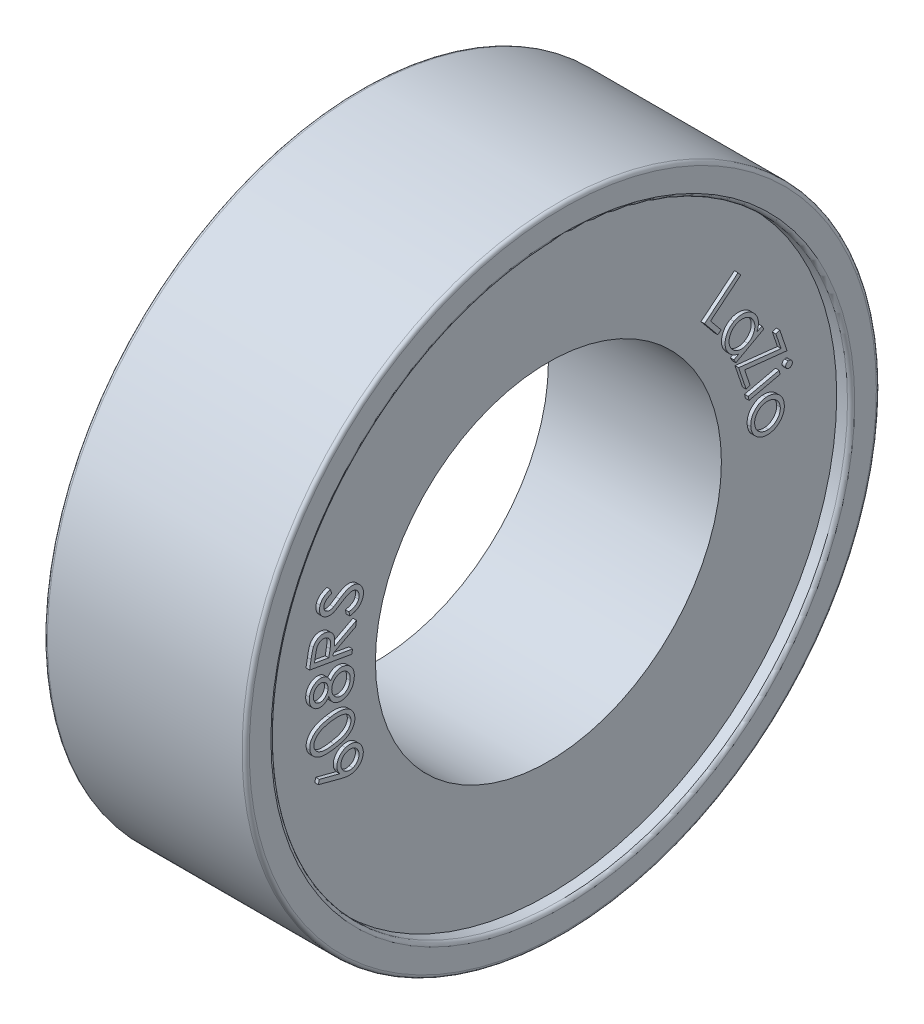
from build123d import *

# Parameters (mm, degrees)
SKETCH1_R           = 10
SKETCH1_R_2         = 6
BOSS_EXTRUDE1_DEPTH = 3
SKETCH1_3_R         = 11
SKETCH1_3_R_2       = 10
BOSS_EXTRUDE2_DEPTH = 3.5
FILLET1_R           = 0.125
BOSS_EXTRUDE3_DEPTH = 0.125
BOSS_EXTRUDE4_DEPTH = 0.125


with BuildPart() as part:
    # Sketch1 → Boss-Extrude1 (new, symmetric)
    with BuildSketch(Plane(origin=(0, 0, 0), x_dir=(0, 0, -1), z_dir=(1, 0, 0))):
        Circle(SKETCH1_R)
        Circle(SKETCH1_R_2, mode=Mode.SUBTRACT)
    extrude(amount=BOSS_EXTRUDE1_DEPTH, both=True)



with BuildPart() as body_2:
    # Sketch1_3 → Boss-Extrude2 (new, symmetric)
    with BuildSketch(Plane(origin=(0, 0, 0), x_dir=(0, 0, -1), z_dir=(1, 0, 0))):
        Circle(SKETCH1_3_R)
        Circle(SKETCH1_3_R_2, mode=Mode.SUBTRACT)
    extrude(amount=BOSS_EXTRUDE2_DEPTH, both=True)

    # Fillet1
    fillet1_edges = [body_2.edges().sort_by_distance(p)[0] for p in [
        (-3.5, 0, 10),
        (3.5, 0, 10),
        (3.5, 0, 11),
        (-3.5, 0, 11),
    ]]
    fillet(fillet1_edges, radius=FILLET1_R)


with BuildPart() as part_1:
    add(part.part)

    add(body_2.part)  # Boss-Extrude3 merges body 2
    # Sketch2 → Boss-Extrude3 (add)
    # profile 1 of 6: a face of its own
    with BuildSketch(Plane(origin=(3, 0, 0), x_dir=(0, 0, -1), z_dir=(1, 0, 0))):
        Polygon((7.876173814, 1.880145542), (7.908024775, 1.741022946), (6.835308429, 1.495530158), (6.803457468, 1.634652754), align=None)
    # profile 2 of 6: a face of its own
    with BuildSketch(Plane(origin=(3, 0, 0), x_dir=(0, 0, -1), z_dir=(1, 0, 0))):
        Polygon((7.765165052, 3.027508204), (7.90128284, 3.073481762), (8.152785244, 2.330392819), (6.681330917, 2.488746185), (6.870934283, 1.929250992), (6.733915052, 1.882976954), (6.470994379, 2.659719742), (7.944552071, 2.497760608), align=None)
    # profile 3 of 6: a face of its own
    with BuildSketch(Plane(origin=(3, 0, 0), x_dir=(0, 0, -1), z_dir=(1, 0, 0))):
        with BuildLine():
            Line((7.348067222, 3.385418884), (6.377514338, 2.854168884))
            Line((6.377514338, 2.854168884), (6.310206645, 2.977065519))
            Line((6.310206645, 2.977065519), (6.476973472, 3.068411673))
            add(Edge.make_bspline(
                [(6.476973472, 3.068411673), (6.432912301, 3.076882848), (6.368707025, 3.094720381), (6.289951586, 3.132117651), (6.23634493, 3.164895224), (6.187594105, 3.20363805), (6.128638882, 3.263733971), (6.091998896, 3.315978449), (6.071624915, 3.353567923)],
                knots=[0, 0, 0, 0, 0.262596255, 0.387041454, 0.508790467, 0.629257764, 0.750192583, 1, 1, 1, 1], degree=3))
            add(Edge.make_bspline(
                [(6.071624915, 3.353567923), (6.053862987, 3.386992389), (6.03048371, 3.438510469), (6.011799468, 3.510747841), (6.003750028, 3.564940911), (6.000958697, 3.619794764), (6.003923914, 3.675313512), (6.013279383, 3.731385415), (6.027465546, 3.787586409), (6.047230542, 3.842211504), (6.071118785, 3.894366115), (6.100316638, 3.942551382), (6.13344444, 3.987746849), (6.171463457, 4.029304679), (6.229103175, 4.080496339), (6.277591205, 4.113261636), (6.312310011, 4.131813115)],
                knots=[0, 0, 0, 0, 0.12543495, 0.18605548, 0.246388948, 0.30646051, 0.367542389, 0.429994028, 0.494310924, 0.559107792, 0.621987258, 0.683837808, 0.745229205, 0.807172064, 0.869852883, 1, 1, 1, 1], degree=3))
            add(Edge.make_bspline(
                [(6.312310011, 4.131813115), (6.346167536, 4.150308861), (6.398885364, 4.173371613), (6.47195978, 4.193368531), (6.526830045, 4.202508054), (6.582318261, 4.205774588), (6.638403949, 4.203376986), (6.6949965, 4.194989636), (6.751549432, 4.181673712), (6.806615153, 4.163143671), (6.85903, 4.140416863), (6.907499996, 4.11266275), (6.952242968, 4.080475083), (6.993840358, 4.044454205), (7.043953259, 3.988714725), (7.076218653, 3.941983784), (7.094160972, 3.908255423)],
                knots=[0, 0, 0, 0, 0.1280267, 0.190038322, 0.251025809, 0.312298894, 0.374184765, 0.436990482, 0.50189608, 0.566753992, 0.629565866, 0.69120574, 0.751719409, 0.812259549, 0.873437884, 1, 1, 1, 1], degree=3))
            add(Edge.make_bspline(
                [(7.094160972, 3.908255423), (7.115257889, 3.870104386), (7.140326856, 3.809999175), (7.157881464, 3.726326645), (7.163188956, 3.663831995), (7.159947329, 3.600845258), (7.145191525, 3.514408491), (7.121470476, 3.451582236), (7.102273953, 3.410659269)],
                knots=[0, 0, 0, 0, 0.252388809, 0.373833537, 0.493677479, 0.614414294, 0.737947537, 1, 1, 1, 1], degree=3))
            Line((7.102273953, 3.410659269), (7.28075953, 3.508315519))
            Line((7.28075953, 3.508315519), (7.348067222, 3.385418884))
        make_face()
        with BuildLine():
            add(Edge.make_bspline(
                [(6.979076838, 3.832534269), (6.960583274, 3.866312744), (6.926929489, 3.913709089), (6.870081876, 3.965543712), (6.822818599, 3.998229251), (6.771849664, 4.0248383), (6.717386415, 4.043914664), (6.66028237, 4.055562812), (6.601313925, 4.060085083), (6.542202387, 4.056939042), (6.465105723, 4.04406133), (6.410589038, 4.022217192), (6.376612895, 4.003808307)],
                knots=[0, 0, 0, 0, 0.166129634, 0.248055287, 0.330600145, 0.413273703, 0.495228948, 0.578574358, 0.663901406, 0.749523051, 0.833234679, 1, 1, 1, 1], degree=3))
            add(Edge.make_bspline(
                [(6.376612895, 4.003808307), (6.342533493, 3.985585894), (6.295564594, 3.950655625), (6.242678081, 3.892880769), (6.208288267, 3.844043935), (6.179845492, 3.791529), (6.158392595, 3.736682152), (6.145184015, 3.680008055), (6.139506876, 3.622426331), (6.141226663, 3.565035601), (6.153715265, 3.490015484), (6.174718897, 3.436763056), (6.192718665, 3.40344773)],
                knots=[0, 0, 0, 0, 0.166299711, 0.250040083, 0.33677935, 0.423140545, 0.506937675, 0.589889477, 0.673200136, 0.75571473, 0.836711587, 1, 1, 1, 1], degree=3))
            add(Edge.make_bspline(
                [(6.192718665, 3.40344773), (6.211315652, 3.369912665), (6.245203252, 3.32266503), (6.302307895, 3.270306027), (6.35011982, 3.236250512), (6.401647383, 3.208424677), (6.455686325, 3.187948142), (6.511441693, 3.175547673), (6.568477855, 3.171083332), (6.626008939, 3.174373082), (6.703434193, 3.189739124), (6.759052427, 3.212364663), (6.794281165, 3.231873211)],
                knots=[0, 0, 0, 0, 0.164964063, 0.247567707, 0.332184894, 0.416782348, 0.498700416, 0.579895142, 0.661555771, 0.743958169, 0.826908066, 1, 1, 1, 1], degree=3))
            add(Edge.make_bspline(
                [(6.794281165, 3.231873211), (6.821183374, 3.246809242), (6.859730545, 3.27161905), (6.904490541, 3.311825464), (6.934604244, 3.343486734), (6.960080786, 3.378525765), (6.98250809, 3.415529576), (7.001221729, 3.455202057), (7.016089288, 3.496875138), (7.02684533, 3.539761068), (7.033571558, 3.582704502), (7.035745237, 3.625413992), (7.033227074, 3.667693212), (7.026655653, 3.709702965), (7.011520056, 3.765997388), (6.993335444, 3.806420939), (6.979076838, 3.832534269)],
                knots=[0, 0, 0, 0, 0.131761822, 0.194869765, 0.257000435, 0.31825815, 0.379747577, 0.441830974, 0.505512033, 0.568679555, 0.630656458, 0.691130331, 0.751199285, 0.811483215, 0.872685488, 1, 1, 1, 1], degree=3))
        make_face(mode=Mode.SUBTRACT)
    # profile 4 of 6: a face of its own
    with BuildSketch(Plane(origin=(3, 0, 0), x_dir=(0, 0, -1), z_dir=(1, 0, 0))):
        Polygon((6.451970007, 5.521097553), (6.54722241, 5.404511014), (5.499145487, 4.546337937), (5.864229622, 4.100424476), (5.752150295, 4.008777841), (5.291813757, 4.571277841), align=None)
    # profile 5 of 6: a face of its own
    with BuildSketch(Plane(origin=(3, 0, 0), x_dir=(0, 0, -1), z_dir=(1, 0, 0))):
        with BuildLine():
            add(Edge.make_bspline(
                [(8.055357572, 0.767794244), (8.059184284, 0.726897516), (8.058144296, 0.666003934), (8.045488516, 0.586954314), (8.02923768, 0.531035823), (8.007553781, 0.477190051), (7.970096763, 0.407403163), (7.932669377, 0.360263326), (7.905417668, 0.330594725)],
                knots=[0, 0, 0, 0, 0.258156998, 0.381466926, 0.502764496, 0.623789911, 0.746181412, 1, 1, 1, 1], degree=3))
            add(Edge.make_bspline(
                [(7.905417668, 0.330594725), (7.879976328, 0.303850369), (7.839051771, 0.266872592), (7.778527786, 0.226257661), (7.731281318, 0.200606223), (7.681624771, 0.179782466), (7.611580084, 0.157858719), (7.556624634, 0.148617755), (7.51929988, 0.145799052)],
                knots=[0, 0, 0, 0, 0.252774475, 0.375817167, 0.498233518, 0.620232449, 0.743845074, 1, 1, 1, 1], degree=3))
            add(Edge.make_bspline(
                [(7.51929988, 0.145799052), (7.481713939, 0.142743109), (7.425539518, 0.143025749), (7.352064745, 0.153832544), (7.299056277, 0.167658421), (7.247144457, 0.185750261), (7.197004175, 0.209909215), (7.148224669, 0.238828494), (7.101285992, 0.272506183), (7.057803001, 0.310633518), (7.018589563, 0.352306252), (6.984865885, 0.397494667), (6.956390689, 0.446126612), (6.932881275, 0.497839168), (6.908379872, 0.572694606), (6.898613481, 0.631896826), (6.895201322, 0.67224136)],
                knots=[0, 0, 0, 0, 0.124270872, 0.184364268, 0.24434146, 0.30459427, 0.365290492, 0.427462078, 0.491327071, 0.555432271, 0.61780079, 0.679606617, 0.740873944, 0.803227606, 0.866497567, 1, 1, 1, 1], degree=3))
            add(Edge.make_bspline(
                [(6.895201322, 0.67224136), (6.891888787, 0.712789676), (6.891735688, 0.773128291), (6.904163742, 0.851200247), (6.918414262, 0.906386982), (6.938772317, 0.959059364), (6.964664891, 1.009208315), (6.996647592, 1.056612022), (7.033364176, 1.101286665), (7.073855498, 1.142473681), (7.117356403, 1.179048684), (7.163157283, 1.210706356), (7.211145144, 1.237566639), (7.261272152, 1.259757038), (7.332020048, 1.282287819), (7.387406876, 1.291805258), (7.424948918, 1.294837513)],
                knots=[0, 0, 0, 0, 0.134008452, 0.197427109, 0.259802779, 0.321276187, 0.382914705, 0.4451866, 0.509142043, 0.573021808, 0.635033942, 0.695942449, 0.756018074, 0.815806221, 0.876071533, 1, 1, 1, 1], degree=3))
            add(Edge.make_bspline(
                [(7.424948918, 1.294837513), (7.462018611, 1.298167889), (7.517458528, 1.297955366), (7.590002416, 1.287916664), (7.642235349, 1.275312925), (7.692884653, 1.257642872), (7.759035677, 1.227612356), (7.805564327, 1.198093796), (7.834804688, 1.175546648)],
                knots=[0, 0, 0, 0, 0.255344777, 0.378927283, 0.501994248, 0.623540367, 0.746616934, 1, 1, 1, 1], degree=3))
            add(Edge.make_bspline(
                [(7.834804688, 1.175546648), (7.867023682, 1.151108877), (7.911335974, 1.110255745), (7.959939322, 1.047547736), (7.990947634, 0.998242433), (8.015537111, 0.945122124), (8.041784601, 0.869176558), (8.05174562, 0.808742047), (8.055357572, 0.767794244)],
                knots=[0, 0, 0, 0, 0.253736058, 0.375519302, 0.496864155, 0.618288685, 0.741877034, 1, 1, 1, 1], degree=3))
        make_face()
        with BuildLine():
            add(Edge.make_bspline(
                [(7.916234976, 0.756375975), (7.913563429, 0.784825479), (7.906816312, 0.827068755), (7.888343415, 0.8803605), (7.870916803, 0.918229244), (7.849115998, 0.953936396), (7.823691763, 0.987964801), (7.794124496, 1.019820552), (7.760859593, 1.049279398), (7.725302676, 1.076101632), (7.687838497, 1.099186863), (7.648808852, 1.117856938), (7.608493489, 1.132672811), (7.566708789, 1.143287342), (7.508495554, 1.15163137), (7.463851349, 1.152062124), (7.433963341, 1.149404821)],
                knots=[0, 0, 0, 0, 0.124131366, 0.184310496, 0.244179873, 0.30460785, 0.365432795, 0.428152289, 0.492772129, 0.557941713, 0.621128956, 0.683311956, 0.745300378, 0.807154671, 0.869949359, 1, 1, 1, 1], degree=3))
            add(Edge.make_bspline(
                [(7.433963341, 1.149404821), (7.395068035, 1.146149458), (7.337324377, 1.13468523), (7.265396838, 1.104090888), (7.215017982, 1.074457088), (7.168851653, 1.039280084), (7.128466849, 0.999003059), (7.094386785, 0.954062008), (7.067111904, 0.904730716), (7.046771858, 0.852225667), (7.028687525, 0.778655127), (7.026704963, 0.721390375), (7.029816707, 0.683359148)],
                knots=[0, 0, 0, 0, 0.170442258, 0.2544837, 0.340111224, 0.424929136, 0.507158968, 0.588300793, 0.670296699, 0.752376476, 0.833386286, 1, 1, 1, 1], degree=3))
            add(Edge.make_bspline(
                [(7.029816707, 0.683359148), (7.032284841, 0.645263555), (7.044781139, 0.589576821), (7.073736506, 0.51971076), (7.102753024, 0.471380795), (7.137771113, 0.427283018), (7.178549942, 0.388269677), (7.224895433, 0.355039927), (7.276239175, 0.327954873), (7.330768942, 0.306931044), (7.406809042, 0.288709471), (7.465601385, 0.286049027), (7.504576322, 0.28942886)],
                knots=[0, 0, 0, 0, 0.166167164, 0.247303675, 0.32927495, 0.411433809, 0.492470089, 0.574874142, 0.659581735, 0.745262385, 0.829371874, 1, 1, 1, 1], degree=3))
            add(Edge.make_bspline(
                [(7.504576322, 0.28942886), (7.534476233, 0.291881438), (7.578611502, 0.299130312), (7.634474047, 0.317654472), (7.673991095, 0.334606651), (7.711247351, 0.355957095), (7.746548411, 0.381034469), (7.779903466, 0.409866143), (7.810659707, 0.442270206), (7.83841112, 0.477005144), (7.862118622, 0.513550991), (7.882401504, 0.550916226), (7.897583021, 0.589848175), (7.908914282, 0.629881244), (7.918116226, 0.685365378), (7.918617744, 0.727983098), (7.916234976, 0.756375975)],
                knots=[0, 0, 0, 0, 0.130233876, 0.192895457, 0.25497576, 0.316473896, 0.378809175, 0.442580425, 0.507432172, 0.57237848, 0.635172512, 0.696212983, 0.756490789, 0.81606117, 0.876426625, 1, 1, 1, 1], degree=3))
        make_face(mode=Mode.SUBTRACT)
    # profile 6 of 6: a face of its own
    with BuildSketch(Plane(origin=(3, 0, 0), x_dir=(0, 0, -1), z_dir=(1, 0, 0))):
        with BuildLine():
            add(Edge.make_bspline(
                [(8.333806025, 1.912296985), (8.336765064, 1.897446884), (8.338914136, 1.873959818), (8.329737705, 1.84444022), (8.319429825, 1.823626357), (8.305379195, 1.804929496), (8.28209068, 1.784496615), (8.26057326, 1.775052676), (8.245464679, 1.771972465)],
                knots=[0, 0, 0, 0, 0.249117155, 0.371430687, 0.499064661, 0.625946242, 0.749600591, 1, 1, 1, 1], degree=3))
            add(Edge.make_bspline(
                [(8.245464679, 1.771972465), (8.230763383, 1.768592647), (8.207723525, 1.76752437), (8.178372711, 1.775987431), (8.15770221, 1.786378234), (8.13899752, 1.800391864), (8.118626782, 1.823619565), (8.109215213, 1.845029351), (8.106041602, 1.860013331)],
                knots=[0, 0, 0, 0, 0.247633667, 0.368743436, 0.497240399, 0.624979881, 0.749470312, 1, 1, 1, 1], degree=3))
            add(Edge.make_bspline(
                [(8.106041602, 1.860013331), (8.102796666, 1.874774103), (8.101311657, 1.898061259), (8.110454423, 1.927346909), (8.120707665, 1.948096386), (8.134763708, 1.966675895), (8.157516971, 1.987160128), (8.178701876, 1.996549689), (8.193481506, 1.999736888)],
                knots=[0, 0, 0, 0, 0.249801647, 0.371625234, 0.500395299, 0.628406273, 0.751929139, 1, 1, 1, 1], degree=3))
            add(Edge.make_bspline(
                [(8.193481506, 1.999736888), (8.208428719, 2.002660136), (8.232026295, 2.004880847), (8.261633718, 1.995663881), (8.282472841, 1.985376663), (8.301015173, 1.971297751), (8.321712321, 1.94862264), (8.330246719, 1.926908593), (8.333806025, 1.912296985)],
                knots=[0, 0, 0, 0, 0.251616485, 0.374360222, 0.502443114, 0.629770967, 0.752634661, 1, 1, 1, 1], degree=3))
        make_face()
    boss_extrude3 = extrude(amount=BOSS_EXTRUDE3_DEPTH)

    # Sketch4 → Boss-Extrude4 (add)
    # profile 1 of 5: a face of its own
    with BuildSketch(Plane(origin=(3, 0, 0), x_dir=(0, 0, -1), z_dir=(1, 0, 0))):
        with BuildLine():
            Line((-7.011638352, 1.941228674), (-7.041385948, 2.086060405))
            add(Edge.make_bspline(
                [(-7.041385948, 2.086060405), (-6.999189148, 2.093026571), (-6.939049017, 2.106640739), (-6.865508848, 2.134904223), (-6.81985023, 2.159549788), (-6.780826987, 2.187869819), (-6.738241827, 2.230352612), (-6.716285381, 2.269326434), (-6.706650371, 2.296697424)],
                knots=[0, 0, 0, 0, 0.309029664, 0.443489335, 0.567781604, 0.682655594, 0.790580454, 1, 1, 1, 1], degree=3))
            add(Edge.make_bspline(
                [(-6.706650371, 2.296697424), (-6.69871505, 2.319794591), (-6.690076521, 2.355756495), (-6.689180664, 2.404744843), (-6.692386723, 2.441143324), (-6.699784287, 2.476513775), (-6.711427561, 2.50975191), (-6.727532085, 2.540250712), (-6.747848597, 2.567446769), (-6.770804188, 2.591846822), (-6.805061489, 2.619205637), (-6.834272853, 2.634165823), (-6.85478739, 2.641048386)],
                knots=[0, 0, 0, 0, 0.17604078, 0.263270306, 0.351550382, 0.438478699, 0.522589002, 0.604153715, 0.685594162, 0.766136813, 0.844585477, 1, 1, 1, 1], degree=3))
            add(Edge.make_bspline(
                [(-6.85478739, 2.641048386), (-6.878599978, 2.649296933), (-6.931351467, 2.658171836), (-6.984026619, 2.649046673), (-7.010436428, 2.641649347)],
                knots=[0, 0, 0, 0, 0.477935315, 1, 1, 1, 1], degree=3))
            add(Edge.make_bspline(
                [(-7.010436428, 2.641649347), (-7.032084619, 2.635898366), (-7.064945013, 2.623015408), (-7.110183865, 2.603423107), (-7.147619374, 2.584151837), (-7.187680138, 2.562569167), (-7.246322637, 2.528445986), (-7.290422342, 2.499580554), (-7.320833063, 2.479690212)],
                knots=[0, 0, 0, 0, 0.19082327, 0.30110578, 0.420820675, 0.550165245, 0.689663337, 1, 1, 1, 1], degree=3))
            add(Edge.make_bspline(
                [(-7.320833063, 2.479690212), (-7.350592662, 2.460071428), (-7.393320066, 2.432179039), (-7.448574844, 2.39831738), (-7.484280945, 2.377653493), (-7.516001447, 2.360036321), (-7.550647453, 2.34302332), (-7.574883255, 2.332229147), (-7.590364313, 2.327646943)],
                knots=[0, 0, 0, 0, 0.344758908, 0.493455668, 0.626712095, 0.743764697, 0.84427525, 1, 1, 1, 1], degree=3))
            add(Edge.make_bspline(
                [(-7.590364313, 2.327646943), (-7.610654263, 2.321041971), (-7.641537478, 2.313866533), (-7.683019024, 2.30892527), (-7.713458444, 2.30773816), (-7.743629128, 2.308822772), (-7.78354879, 2.314231222), (-7.812937851, 2.32162033), (-7.831950852, 2.328548386)],
                knots=[0, 0, 0, 0, 0.260143321, 0.385642153, 0.509156191, 0.631449242, 0.753461146, 1, 1, 1, 1], degree=3))
            add(Edge.make_bspline(
                [(-7.831950852, 2.328548386), (-7.861303718, 2.339357557), (-7.904076499, 2.359310132), (-7.952787908, 2.39789423), (-7.985148227, 2.430608664), (-8.012370107, 2.467495601), (-8.034339862, 2.507717513), (-8.050657207, 2.550990782), (-8.060979523, 2.596913669), (-8.065811242, 2.644231757), (-8.064337698, 2.708310116), (-8.053189546, 2.755462317), (-8.042888352, 2.785880116)],
                knots=[0, 0, 0, 0, 0.167519363, 0.249059235, 0.330763873, 0.412608477, 0.493038911, 0.574804814, 0.658761795, 0.743711501, 0.82825604, 1, 1, 1, 1], degree=3))
            add(Edge.make_bspline(
                [(-8.042888352, 2.785880116), (-8.031322851, 2.81831542), (-8.008459199, 2.865118998), (-7.96560789, 2.919276241), (-7.934763332, 2.950164532), (-7.906488647, 2.972809143), (-7.882447386, 2.989385669), (-7.855492546, 3.004782519), (-7.826282169, 3.020349445), (-7.794167834, 3.03482593), (-7.746485584, 3.05441221), (-7.708674955, 3.066833245), (-7.682611909, 3.074942616)],
                knots=[0, 0, 0, 0, 0.214698089, 0.32089837, 0.428972982, 0.485772709, 0.546336026, 0.610639354, 0.679005404, 0.752421936, 0.829923101, 1, 1, 1, 1], degree=3))
            Line((-7.682611909, 3.074942616), (-7.635736909, 2.929509924))
            add(Edge.make_bspline(
                [(-7.635736909, 2.929509924), (-7.656192219, 2.922487103), (-7.686041613, 2.912829308), (-7.723449114, 2.897765806), (-7.74804471, 2.887042822), (-7.77020799, 2.876289421), (-7.789580987, 2.865046115), (-7.806966944, 2.854491673), (-7.826016416, 2.839572704), (-7.846802665, 2.819847291), (-7.875418264, 2.784601026), (-7.890264615, 2.753674483), (-7.898056621, 2.732394539)],
                knots=[0, 0, 0, 0, 0.189766663, 0.274923552, 0.353598319, 0.425104112, 0.49081079, 0.550037175, 0.603279713, 0.702703188, 0.800802079, 1, 1, 1, 1], degree=3))
            add(Edge.make_bspline(
                [(-7.898056621, 2.732394539), (-7.906877979, 2.706143087), (-7.915462729, 2.665173906), (-7.908616959, 2.61134166), (-7.896327701, 2.574395506), (-7.877396401, 2.541123103), (-7.843828364, 2.503236137), (-7.810252271, 2.484460095), (-7.786578255, 2.476084443)],
                knots=[0, 0, 0, 0, 0.267611967, 0.392726518, 0.517518556, 0.639529123, 0.758147866, 1, 1, 1, 1], degree=3))
            add(Edge.make_bspline(
                [(-7.786578255, 2.476084443), (-7.771459731, 2.470479831), (-7.747788301, 2.465227747), (-7.715492888, 2.462683316), (-7.690391585, 2.463651782), (-7.663760624, 2.467645462), (-7.62361596, 2.478600323), (-7.593157418, 2.490838827), (-7.572635948, 2.501024347)],
                knots=[0, 0, 0, 0, 0.217705713, 0.326461485, 0.437698315, 0.55694839, 0.690118867, 1, 1, 1, 1], degree=3))
            add(Edge.make_bspline(
                [(-7.572635948, 2.501024347), (-7.563482553, 2.505541181), (-7.548406459, 2.515090861), (-7.525203964, 2.529119048), (-7.50178456, 2.544336332), (-7.474033759, 2.562303338), (-7.429100663, 2.592664584), (-7.393155892, 2.616670448), (-7.368008544, 2.633836847)],
                knots=[0, 0, 0, 0, 0.125280758, 0.219260052, 0.333345188, 0.468592883, 0.62569115, 1, 1, 1, 1], degree=3))
            add(Edge.make_bspline(
                [(-7.368008544, 2.633836847), (-7.336662754, 2.654876196), (-7.290881508, 2.684998425), (-7.229613449, 2.720446864), (-7.18748894, 2.742828295), (-7.147652055, 2.762440575), (-7.109813637, 2.778169081), (-7.07439305, 2.79148004), (-7.040650137, 2.800825085), (-7.00837196, 2.807365237), (-6.977126053, 2.812432163), (-6.946476786, 2.814725213), (-6.916559586, 2.815097154), (-6.887436795, 2.81328581), (-6.849622471, 2.80822509), (-6.822215859, 2.800440276), (-6.804306621, 2.794594059)],
                knots=[0, 0, 0, 0, 0.186084148, 0.269899677, 0.348729984, 0.421139088, 0.488610313, 0.550601391, 0.607487179, 0.660923414, 0.712861397, 0.763362853, 0.812231396, 0.860201761, 0.907041439, 1, 1, 1, 1], degree=3))
            add(Edge.make_bspline(
                [(-6.804306621, 2.794594059), (-6.779384777, 2.785989938), (-6.743763613, 2.76917667), (-6.70025545, 2.740538064), (-6.670617581, 2.715736103), (-6.643842738, 2.687540056), (-6.619321875, 2.656402843), (-6.597411111, 2.622072709), (-6.578362995, 2.585035962), (-6.562466771, 2.546251405), (-6.550529767, 2.506589295), (-6.542052797, 2.466613531), (-6.538671848, 2.426174322), (-6.538945516, 2.385436993), (-6.544612343, 2.329959038), (-6.555343772, 2.288962267), (-6.564823448, 2.262142136)],
                knots=[0, 0, 0, 0, 0.121894261, 0.181421904, 0.240656421, 0.300328285, 0.361070903, 0.423823304, 0.488509801, 0.553588768, 0.617526801, 0.679984008, 0.742349972, 0.804932635, 0.868310301, 1, 1, 1, 1], degree=3))
            add(Edge.make_bspline(
                [(-6.564823448, 2.262142136), (-6.572758291, 2.241441795), (-6.584673949, 2.210383128), (-6.606887575, 2.172597606), (-6.624600633, 2.145528085), (-6.644392639, 2.120197446), (-6.665940643, 2.096057066), (-6.689575077, 2.073793756), (-6.715039376, 2.052717769), (-6.742960881, 2.033465998), (-6.77319189, 2.015426164), (-6.806276685, 1.999134303), (-6.842055855, 1.984503052), (-6.880594238, 1.971307138), (-6.937033888, 1.955324667), (-6.981250132, 1.946284172), (-7.011638352, 1.941228674)],
                knots=[0, 0, 0, 0, 0.114729196, 0.170788225, 0.226006166, 0.281655852, 0.336582454, 0.392912727, 0.449126573, 0.507080718, 0.567830534, 0.630734282, 0.697283978, 0.767276625, 0.840936454, 1, 1, 1, 1], degree=3))
        make_face()
    # profile 2 of 5: a face of its own
    with BuildSketch(Plane(origin=(3, 0, 0), x_dir=(0, 0, -1), z_dir=(1, 0, 0))):
        with BuildLine():
            Line((-8.408067858, 1.01721813), (-8.357286608, 1.308984957))
            add(Edge.make_bspline(
                [(-8.357286608, 1.308984957), (-8.350617936, 1.346385285), (-8.3411862, 1.400051656), (-8.326818614, 1.46782324), (-8.316913337, 1.511201231), (-8.307399187, 1.549600162), (-8.295887672, 1.591045365), (-8.286629571, 1.619398352), (-8.279462089, 1.636208515)],
                knots=[0, 0, 0, 0, 0.338375124, 0.485158431, 0.616939651, 0.734632706, 0.837436261, 1, 1, 1, 1], degree=3))
            add(Edge.make_bspline(
                [(-8.279462089, 1.636208515), (-8.271073105, 1.656540378), (-8.255869767, 1.685524154), (-8.232222567, 1.721746552), (-8.212276257, 1.746295641), (-8.190704796, 1.769123811), (-8.1673787, 1.790149813), (-8.141931031, 1.809083246), (-8.115018053, 1.82626546), (-8.086532785, 1.84088703), (-8.056957093, 1.85312634), (-8.026185523, 1.862026037), (-7.994523041, 1.868354663), (-7.961952562, 1.872043734), (-7.916525468, 1.872672595), (-7.882120811, 1.869140328), (-7.859089493, 1.865174861)],
                knots=[0, 0, 0, 0, 0.126763836, 0.188483442, 0.249325304, 0.309019679, 0.369597394, 0.430288062, 0.491864054, 0.553648582, 0.614829948, 0.676283742, 0.738176322, 0.800985165, 0.865154285, 1, 1, 1, 1], degree=3))
            add(Edge.make_bspline(
                [(-7.859089493, 1.865174861), (-7.821233685, 1.858756084), (-7.766375342, 1.842616654), (-7.701019253, 1.806210755), (-7.657920842, 1.773430124), (-7.620337092, 1.734938836), (-7.589742071, 1.690604349), (-7.565410235, 1.641492028), (-7.55136202, 1.596622419), (-7.54339578, 1.558068973), (-7.539267327, 1.5264315), (-7.536959051, 1.492519723), (-7.536273895, 1.45640512), (-7.538081415, 1.418124564), (-7.541925311, 1.362431396), (-7.548477464, 1.319780217), (-7.55320007, 1.29065563)],
                knots=[0, 0, 0, 0, 0.15573696, 0.229158099, 0.302153748, 0.374503054, 0.446241556, 0.519590828, 0.595854893, 0.63606234, 0.679066444, 0.725055894, 0.77377908, 0.825377234, 0.880333361, 1, 1, 1, 1], degree=3))
            Line((-7.55320007, 1.29065563), (-6.780363531, 1.698708515))
            Line((-6.780363531, 1.698708515), (-6.811914012, 1.517518611))
            Line((-6.811914012, 1.517518611), (-7.58445007, 1.110667649))
            Line((-7.58445007, 1.110667649), (-7.599173627, 1.026833515))
            Line((-7.599173627, 1.026833515), (-6.918284204, 0.908143611))
            Line((-6.918284204, 0.908143611), (-6.94382507, 0.761809476))
            Line((-6.94382507, 0.761809476), (-8.408067858, 1.01721813))
        make_face()
        with BuildLine():
            Line((-8.239197666, 1.138612361), (-7.741301031, 1.051773419))
            Line((-7.741301031, 1.051773419), (-7.695627954, 1.303275822))
            add(Edge.make_bspline(
                [(-7.695627954, 1.303275822), (-7.69184716, 1.326143248), (-7.68634332, 1.35928484), (-7.682416689, 1.40231004), (-7.680096871, 1.431040755), (-7.67939821, 1.457632001), (-7.680466105, 1.481883815), (-7.681978138, 1.504009534), (-7.686455238, 1.530189474), (-7.694842262, 1.560372906), (-7.710103154, 1.593594765), (-7.730048658, 1.623838964), (-7.755272549, 1.650031612), (-7.78357803, 1.672984432), (-7.826190778, 1.69734287), (-7.86147465, 1.708683301), (-7.885832281, 1.712831111)],
                knots=[0, 0, 0, 0, 0.13514722, 0.19555273, 0.251738302, 0.303118633, 0.350432101, 0.393187105, 0.432243814, 0.505047113, 0.575046887, 0.64449936, 0.715109777, 0.786124374, 0.856209278, 1, 1, 1, 1], degree=3))
            add(Edge.make_bspline(
                [(-7.885832281, 1.712831111), (-7.909459589, 1.717129053), (-7.945777046, 1.718578278), (-7.992890239, 1.709099396), (-8.026662395, 1.697121818), (-8.058199032, 1.680716108), (-8.086378007, 1.66005832), (-8.111161417, 1.63578748), (-8.12846551, 1.611929055), (-8.140242484, 1.589888849), (-8.149337586, 1.57073694), (-8.15764824, 1.548569088), (-8.165722678, 1.523593238), (-8.173495683, 1.495837622), (-8.183349439, 1.453192773), (-8.190461277, 1.419847428), (-8.19412555, 1.396424861)],
                knots=[0, 0, 0, 0, 0.142972422, 0.213479107, 0.284947223, 0.35561757, 0.424306003, 0.492182327, 0.561352934, 0.598705367, 0.640846895, 0.687461956, 0.73949983, 0.797073442, 0.858967364, 1, 1, 1, 1], degree=3))
            Line((-8.19412555, 1.396424861), (-8.239197666, 1.138612361))
        make_face(mode=Mode.SUBTRACT)
    # profile 3 of 5: a face of its own
    with BuildSketch(Plane(origin=(3, 0, 0), x_dir=(0, 0, -1), z_dir=(1, 0, 0))):
        with BuildLine():
            Line((-8.105571042, -2.577164781), (-8.06951335, -2.435037377))
            Line((-8.06951335, -2.435037377), (-7.3624821, -2.618030166))
            add(Edge.make_bspline(
                [(-7.3624821, -2.618030166), (-7.37949823, -2.596918371), (-7.407266467, -2.553314172), (-7.430087703, -2.506882348), (-7.437602292, -2.483414781)],
                knots=[0, 0, 0, 0, 0.524252626, 1, 1, 1, 1], degree=3))
            add(Edge.make_bspline(
                [(-7.437602292, -2.483414781), (-7.44693676, -2.456427088), (-7.457377062, -2.415076638), (-7.461615522, -2.359178406), (-7.46124445, -2.318094618), (-7.456004378, -2.277186017), (-7.446338302, -2.236628842), (-7.432339731, -2.196417382), (-7.414423791, -2.156937965), (-7.392719052, -2.119255895), (-7.367888822, -2.083944303), (-7.339956733, -2.051876049), (-7.309056922, -2.022647695), (-7.274942037, -1.996943165), (-7.225141943, -1.965612165), (-7.183703836, -1.948594605), (-7.15545085, -1.938342666)],
                knots=[0, 0, 0, 0, 0.125365399, 0.185748852, 0.245505721, 0.305285195, 0.366239735, 0.428068331, 0.491771295, 0.556128413, 0.618539614, 0.680823886, 0.742363032, 0.804751034, 0.867900128, 1, 1, 1, 1], degree=3))
            add(Edge.make_bspline(
                [(-7.15545085, -1.938342666), (-7.116550718, -1.925014381), (-7.056445394, -1.911690385), (-6.975420602, -1.910822183), (-6.916309467, -1.918438896), (-6.858947828, -1.933648618), (-6.804135364, -1.956815649), (-6.752489288, -1.987689714), (-6.704684202, -2.025959359), (-6.661223187, -2.069715063), (-6.611412139, -2.1355352), (-6.583746097, -2.191195567), (-6.570715273, -2.230409973)],
                knots=[0, 0, 0, 0, 0.169399241, 0.251067303, 0.332561253, 0.414097984, 0.49468408, 0.576806004, 0.661058717, 0.746220147, 0.8301127, 1, 1, 1, 1], degree=3))
            add(Edge.make_bspline(
                [(-6.570715273, -2.230409973), (-6.558048223, -2.268060549), (-6.544987894, -2.326582623), (-6.544905, -2.406012659), (-6.551996462, -2.464892522), (-6.566647273, -2.522344815), (-6.588918228, -2.577036878), (-6.619619469, -2.627867065), (-6.656585266, -2.67517708), (-6.699791735, -2.717307389), (-6.763514056, -2.765884595), (-6.817702722, -2.792369203), (-6.855571042, -2.804929204)],
                knots=[0, 0, 0, 0, 0.167097627, 0.249144412, 0.332644448, 0.415609567, 0.497494368, 0.579754482, 0.664260801, 0.749056762, 0.832534535, 1, 1, 1, 1], degree=3))
            add(Edge.make_bspline(
                [(-6.855571042, -2.804929204), (-6.88518252, -2.815286518), (-6.932241404, -2.825936198), (-6.997487866, -2.832072695), (-7.040879623, -2.832779079), (-7.077379427, -2.831324486), (-7.106895273, -2.828288269), (-7.138350838, -2.825079345), (-7.171407251, -2.819215565), (-7.206355688, -2.813177148), (-7.256589109, -2.802166339), (-7.295119209, -2.793007704), (-7.321316235, -2.785998916)],
                knots=[0, 0, 0, 0, 0.198655611, 0.30457131, 0.415095671, 0.473580356, 0.536082374, 0.603202284, 0.673992779, 0.748862248, 0.828084835, 1, 1, 1, 1], degree=3))
            Line((-7.321316235, -2.785998916), (-8.105571042, -2.577164781))
        make_face()
        with BuildLine():
            add(Edge.make_bspline(
                [(-7.302686427, -2.474400358), (-7.295828421, -2.494089494), (-7.283498843, -2.522754465), (-7.261110314, -2.557197663), (-7.24228818, -2.580729682), (-7.221653504, -2.602709504), (-7.197868592, -2.621749955), (-7.172301305, -2.639397882), (-7.144570554, -2.654497838), (-7.11560544, -2.667073559), (-7.08603116, -2.676740293), (-7.056265622, -2.68347189), (-7.026230534, -2.686735247), (-6.996040061, -2.687021015), (-6.954884579, -2.683433202), (-6.924479358, -2.675554034), (-6.904549408, -2.668811416)],
                knots=[0, 0, 0, 0, 0.127029796, 0.188750541, 0.249494083, 0.310289609, 0.37179924, 0.434532333, 0.49919379, 0.563633582, 0.626482094, 0.688308126, 0.74903331, 0.809999764, 0.871816779, 1, 1, 1, 1], degree=3))
            add(Edge.make_bspline(
                [(-6.904549408, -2.668811416), (-6.884881579, -2.661927633), (-6.856154609, -2.64967306), (-6.821744962, -2.627121109), (-6.797938143, -2.608620238), (-6.776257727, -2.587654535), (-6.757182512, -2.564012213), (-6.739556839, -2.538421101), (-6.724450119, -2.510696893), (-6.711878397, -2.481730281), (-6.702233153, -2.452248503), (-6.695538331, -2.422574372), (-6.69184907, -2.392682497), (-6.691520397, -2.36253849), (-6.69590514, -2.321688276), (-6.702746341, -2.29133227), (-6.709837869, -2.271575839)],
                knots=[0, 0, 0, 0, 0.127252252, 0.189081082, 0.250410247, 0.310872796, 0.372490142, 0.435333094, 0.500107787, 0.564660425, 0.627618998, 0.688957284, 0.749859276, 0.810932495, 0.872307253, 1, 1, 1, 1], degree=3))
            add(Edge.make_bspline(
                [(-6.709837869, -2.271575839), (-6.716721652, -2.25190801), (-6.728976225, -2.22318104), (-6.751528175, -2.188771393), (-6.770029047, -2.164964575), (-6.79099475, -2.143284158), (-6.814637072, -2.124208944), (-6.840228184, -2.10658327), (-6.867952392, -2.09147655), (-6.896919004, -2.078904828), (-6.926400782, -2.069259584), (-6.956074912, -2.062564762), (-6.985966788, -2.058875501), (-7.016110795, -2.058546828), (-7.056961009, -2.062931571), (-7.087317015, -2.069772772), (-7.107073446, -2.0768643)],
                knots=[0, 0, 0, 0, 0.127252252, 0.189081082, 0.250410247, 0.310872796, 0.372490142, 0.435333094, 0.500107787, 0.564660425, 0.627618998, 0.688957284, 0.749859276, 0.810932495, 0.872307253, 1, 1, 1, 1], degree=3))
            add(Edge.make_bspline(
                [(-7.107073446, -2.0768643), (-7.127008662, -2.083734316), (-7.15571329, -2.096352098), (-7.190552721, -2.118527846), (-7.2143991, -2.137049992), (-7.235847773, -2.158419588), (-7.255385442, -2.181842749), (-7.272945885, -2.207574153), (-7.288077304, -2.235274404), (-7.300655039, -2.264246248), (-7.310253082, -2.293730994), (-7.31712239, -2.323377436), (-7.320157519, -2.353320986), (-7.321142966, -2.383431189), (-7.316522361, -2.42429142), (-7.309828584, -2.454642096), (-7.302686427, -2.474400358)],
                knots=[0, 0, 0, 0, 0.128387867, 0.189777123, 0.250996644, 0.311777529, 0.373673196, 0.436403797, 0.501062686, 0.565499918, 0.628345934, 0.68957456, 0.750297332, 0.811270509, 0.872535541, 1, 1, 1, 1], degree=3))
        make_face(mode=Mode.SUBTRACT)
    # profile 4 of 5: a face of its own
    with BuildSketch(Plane(origin=(3, 0, 0), x_dir=(0, 0, -1), z_dir=(1, 0, 0))):
        with BuildLine():
            add(Edge.make_bspline(
                [(-7.681505358, 0.323226582), (-7.666747424, 0.345509727), (-7.643186253, 0.376805626), (-7.610148371, 0.415557057), (-7.585386134, 0.440878066), (-7.560443444, 0.463515555), (-7.535165313, 0.483434789), (-7.509576133, 0.500661985), (-7.475279267, 0.519845075), (-7.430605305, 0.537855054), (-7.35521018, 0.555959078), (-7.296324193, 0.55611334), (-7.257526993, 0.550690524)],
                knots=[0, 0, 0, 0, 0.156963353, 0.229995123, 0.299085631, 0.364925938, 0.427800454, 0.488035613, 0.546002455, 0.658467493, 0.769816605, 1, 1, 1, 1], degree=3))
            add(Edge.make_bspline(
                [(-7.257526993, 0.550690524), (-7.229891873, 0.546469543), (-7.188794558, 0.538527356), (-7.137160751, 0.518919644), (-7.100059411, 0.502151416), (-7.065051411, 0.481036567), (-7.020139328, 0.448670437), (-6.989434261, 0.420053239), (-6.970868339, 0.398947735)],
                knots=[0, 0, 0, 0, 0.253617938, 0.376396753, 0.4993094, 0.621682477, 0.74573682, 1, 1, 1, 1], degree=3))
            add(Edge.make_bspline(
                [(-6.970868339, 0.398947735), (-6.947324029, 0.373339518), (-6.917595912, 0.330295507), (-6.888289047, 0.267085778), (-6.872190387, 0.216693916), (-6.861209763, 0.163320703), (-6.854573031, 0.086199955), (-6.857961412, 0.026783741), (-6.863296223, -0.01331188)],
                knots=[0, 0, 0, 0, 0.236579866, 0.353837473, 0.473619995, 0.596221496, 0.724369452, 1, 1, 1, 1], degree=3))
            add(Edge.make_bspline(
                [(-6.863296223, -0.01331188), (-6.868743936, -0.051698116), (-6.879483789, -0.107767023), (-6.904303157, -0.177387888), (-6.925727778, -0.224190668), (-6.952000166, -0.266129068), (-6.981310003, -0.304470744), (-7.015328026, -0.337906829), (-7.052561465, -0.366884054), (-7.091734909, -0.391527737), (-7.131618336, -0.412460691), (-7.171893225, -0.429382727), (-7.21263309, -0.442123052), (-7.253721048, -0.450528047), (-7.309173268, -0.456615105), (-7.351167274, -0.45525324), (-7.378921223, -0.451412842)],
                knots=[0, 0, 0, 0, 0.1537013, 0.224809316, 0.292215962, 0.3570268, 0.420319483, 0.482843666, 0.545267186, 0.606758154, 0.665816803, 0.723402241, 0.779461755, 0.834518092, 0.889164549, 1, 1, 1, 1], degree=3))
            add(Edge.make_bspline(
                [(-7.378921223, -0.451412842), (-7.399128763, -0.448811566), (-7.428811547, -0.442590044), (-7.466913423, -0.430463427), (-7.494175177, -0.41961595), (-7.520392409, -0.406641726), (-7.545576018, -0.391624151), (-7.569780405, -0.374658784), (-7.593060763, -0.355761177), (-7.614989076, -0.334180403), (-7.636292337, -0.310426342), (-7.655884552, -0.283505846), (-7.674931675, -0.254268827), (-7.692955416, -0.222387119), (-7.715963968, -0.174965755), (-7.730382695, -0.137076305), (-7.739498147, -0.11096813)],
                knots=[0, 0, 0, 0, 0.116139384, 0.172502731, 0.227873174, 0.283308402, 0.339148293, 0.39492972, 0.451760055, 0.509929627, 0.570222862, 0.633515416, 0.699585079, 0.769161951, 0.842227293, 1, 1, 1, 1], degree=3))
            add(Edge.make_bspline(
                [(-7.739498147, -0.11096813), (-7.761592332, -0.142294986), (-7.798022194, -0.185539599), (-7.855733252, -0.230615093), (-7.900033592, -0.255961659), (-7.945790163, -0.274167616), (-8.007783717, -0.28931563), (-8.05569047, -0.289380969), (-8.086853916, -0.285547457)],
                knots=[0, 0, 0, 0, 0.2811602, 0.410276766, 0.534465497, 0.653649071, 0.769824228, 1, 1, 1, 1], degree=3))
            add(Edge.make_bspline(
                [(-8.086853916, -0.285547457), (-8.119343864, -0.281732302), (-8.166880144, -0.266630455), (-8.226230351, -0.234741447), (-8.268697237, -0.203186436), (-8.308031606, -0.166113873), (-8.341536142, -0.122993662), (-8.370159353, -0.075669121), (-8.392025479, -0.023528125), (-8.408365555, 0.031241337), (-8.42033505, 0.107530024), (-8.419416292, 0.165723913), (-8.414077473, 0.204236197)],
                knots=[0, 0, 0, 0, 0.149699391, 0.227183951, 0.308892449, 0.392286578, 0.474934641, 0.559213066, 0.645874039, 0.734192173, 0.821419164, 1, 1, 1, 1], degree=3))
            add(Edge.make_bspline(
                [(-8.414077473, 0.204236197), (-8.409039992, 0.241561065), (-8.395600256, 0.296705632), (-8.363288734, 0.364388157), (-8.3336999, 0.411514499), (-8.298728404, 0.454122656), (-8.258975227, 0.491003169), (-8.215493247, 0.522469616), (-8.167973968, 0.546720925), (-8.118716622, 0.565188383), (-8.052046765, 0.580162286), (-8.001040059, 0.580501889), (-7.967863531, 0.576231389)],
                knots=[0, 0, 0, 0, 0.17550451, 0.261648254, 0.348194894, 0.433988354, 0.517459378, 0.600013685, 0.683018449, 0.765045644, 0.844349131, 1, 1, 1, 1], degree=3))
            add(Edge.make_bspline(
                [(-7.967863531, 0.576231389), (-7.936000074, 0.57162465), (-7.888844971, 0.559828544), (-7.833104312, 0.528667143), (-7.795178668, 0.499926521), (-7.760942983, 0.464782051), (-7.718419918, 0.408016069), (-7.695162878, 0.358097449), (-7.681505358, 0.323226582)],
                knots=[0, 0, 0, 0, 0.240514826, 0.356344444, 0.473437309, 0.593679956, 0.720465837, 1, 1, 1, 1], degree=3))
        make_face()
        with BuildLine():
            add(Edge.make_bspline(
                [(-8.271649589, 0.177793889), (-8.273825625, 0.15838375), (-8.276295905, 0.12940116), (-8.273194433, 0.091533238), (-8.269129797, 0.064430888), (-8.262276631, 0.038431434), (-8.252639358, 0.013544721), (-8.2414828, -0.010659881), (-8.227170185, -0.033253482), (-8.211621477, -0.05446089), (-8.194204286, -0.073189759), (-8.176034216, -0.089901441), (-8.156187295, -0.103747306), (-8.135505769, -0.115519928), (-8.105982785, -0.128294881), (-8.082262477, -0.133728841), (-8.066120743, -0.135908034)],
                knots=[0, 0, 0, 0, 0.140663519, 0.207791254, 0.27263828, 0.337409366, 0.400507168, 0.464254363, 0.528571952, 0.592343523, 0.652962314, 0.712079733, 0.769395111, 0.826443221, 0.882865839, 1, 1, 1, 1], degree=3))
            add(Edge.make_bspline(
                [(-8.066120743, -0.135908034), (-8.049897777, -0.137726871), (-8.025289647, -0.138856348), (-7.992873236, -0.134008741), (-7.9690235, -0.127122358), (-7.945203558, -0.11818645), (-7.92159344, -0.10637949), (-7.89848115, -0.091492166), (-7.875859769, -0.074221458), (-7.854497111, -0.054980746), (-7.835129863, -0.034203583), (-7.81828645, -0.012072461), (-7.803347849, 0.010967363), (-7.791451586, 0.035613819), (-7.777796253, 0.069939428), (-7.772384682, 0.097457017), (-7.769546223, 0.115894851)],
                knots=[0, 0, 0, 0, 0.114368221, 0.171043025, 0.228496266, 0.287699836, 0.34879657, 0.412739258, 0.479718693, 0.54767662, 0.613610966, 0.678069714, 0.742012402, 0.805303127, 0.869184376, 1, 1, 1, 1], degree=3))
            add(Edge.make_bspline(
                [(-7.769546223, 0.115894851), (-7.766418829, 0.139903927), (-7.766337966, 0.176492528), (-7.775087257, 0.22447197), (-7.786640739, 0.25952744), (-7.802015746, 0.292901981), (-7.821420095, 0.323786091), (-7.845032054, 0.351183227), (-7.871964412, 0.375037088), (-7.901033153, 0.395000276), (-7.940360562, 0.416401996), (-7.972519048, 0.424850326), (-7.993704877, 0.42809437)],
                knots=[0, 0, 0, 0, 0.170726286, 0.256289127, 0.343265846, 0.430572421, 0.515112561, 0.59985351, 0.684991719, 0.768343841, 0.848363762, 1, 1, 1, 1], degree=3))
            add(Edge.make_bspline(
                [(-7.993704877, 0.42809437), (-8.023262262, 0.432675602), (-8.06930406, 0.428152698), (-8.127350658, 0.405176698), (-8.162351635, 0.383077202), (-8.188725945, 0.361083016), (-8.207376529, 0.342164759), (-8.223161637, 0.320289666), (-8.237092731, 0.296306877), (-8.249131656, 0.270071753), (-8.262749235, 0.230833668), (-8.26851351, 0.199333257), (-8.271649589, 0.177793889)],
                knots=[0, 0, 0, 0, 0.213392789, 0.325501099, 0.44608917, 0.508922063, 0.572022201, 0.636353458, 0.702133226, 0.771034637, 0.843399644, 1, 1, 1, 1], degree=3))
        make_face(mode=Mode.SUBTRACT)
        with BuildLine():
            add(Edge.make_bspline(
                [(-7.6355318, 0.100269851), (-7.63927502, 0.075703011), (-7.64055153, 0.038956961), (-7.636865811, -0.009270429), (-7.6300211, -0.043626254), (-7.620488361, -0.076890134), (-7.607458325, -0.109052373), (-7.590813435, -0.139925032), (-7.571388426, -0.169461162), (-7.549782226, -0.197036068), (-7.525729644, -0.221260053), (-7.501052507, -0.243282009), (-7.474177129, -0.26115295), (-7.446489719, -0.276914639), (-7.40674073, -0.292791067), (-7.3753796, -0.300454144), (-7.35398132, -0.303275822)],
                knots=[0, 0, 0, 0, 0.136072324, 0.201160115, 0.264973021, 0.327937656, 0.390808667, 0.454985048, 0.52007748, 0.584626989, 0.646814402, 0.707205257, 0.765744444, 0.823559279, 0.881736119, 1, 1, 1, 1], degree=3))
            add(Edge.make_bspline(
                [(-7.35398132, -0.303275822), (-7.327311101, -0.306967103), (-7.286401981, -0.306865148), (-7.233114141, -0.295007206), (-7.193938022, -0.28069612), (-7.156742438, -0.260855168), (-7.122482089, -0.23617109), (-7.092072106, -0.206152339), (-7.065355487, -0.171462213), (-7.042492154, -0.132441535), (-7.017936501, -0.07337596), (-7.006668836, -0.025663452), (-7.0027193, 0.007421293)],
                knots=[0, 0, 0, 0, 0.153885657, 0.231292722, 0.311202139, 0.391657746, 0.471624617, 0.551818844, 0.635107313, 0.721356296, 0.809650162, 1, 1, 1, 1], degree=3))
            add(Edge.make_bspline(
                [(-7.0027193, 0.007421293), (-6.99891165, 0.03307079), (-6.997062615, 0.071129296), (-7.000617999, 0.1208031), (-7.006483888, 0.155581642), (-7.016033267, 0.188615233), (-7.028153009, 0.220147027), (-7.044399403, 0.24966156), (-7.06324081, 0.277504778), (-7.084392513, 0.303146803), (-7.107270132, 0.326046674), (-7.131504621, 0.346098598), (-7.157178162, 0.363300874), (-7.184292242, 0.377852998), (-7.222797003, 0.393192104), (-7.253360037, 0.400010368), (-7.274053435, 0.402853985)],
                knots=[0, 0, 0, 0, 0.145017611, 0.212489055, 0.278488407, 0.342026922, 0.404706147, 0.467174364, 0.530156297, 0.592684875, 0.652947677, 0.711097196, 0.768479372, 0.825669478, 0.883037957, 1, 1, 1, 1], degree=3))
            add(Edge.make_bspline(
                [(-7.274053435, 0.402853985), (-7.294232882, 0.40519253), (-7.324844354, 0.40685404), (-7.364879511, 0.400888152), (-7.394472627, 0.393747935), (-7.423463034, 0.382747171), (-7.452222999, 0.368935203), (-7.48028237, 0.351547578), (-7.507564986, 0.331403418), (-7.533274413, 0.308746104), (-7.556533983, 0.284010689), (-7.576983397, 0.257564098), (-7.594656383, 0.229448061), (-7.60889975, 0.199452213), (-7.6254892, 0.157139447), (-7.632573323, 0.123265216), (-7.6355318, 0.100269851)],
                knots=[0, 0, 0, 0, 0.117060655, 0.174622914, 0.232150615, 0.291716325, 0.352482943, 0.415280098, 0.481142813, 0.547216546, 0.611975487, 0.67600095, 0.739100857, 0.802441925, 0.866591508, 1, 1, 1, 1], degree=3))
        make_face(mode=Mode.SUBTRACT)
    # profile 5 of 5: a face of its own
    with BuildSketch(Plane(origin=(3, 0, 0), x_dir=(0, 0, -1), z_dir=(1, 0, 0))):
        with BuildLine():
            add(Edge.make_bspline(
                [(-7.536836038, -1.769019784), (-7.582812752, -1.776651672), (-7.650108235, -1.78612996), (-7.737577159, -1.793685258), (-7.797322677, -1.796382244), (-7.853266929, -1.796860778), (-7.90543671, -1.79455485), (-7.953821104, -1.789531864), (-7.99859333, -1.781733528), (-8.04032726, -1.771264009), (-8.079765208, -1.759456543), (-8.116970374, -1.745179596), (-8.152021733, -1.729052742), (-8.185021178, -1.710971205), (-8.215772263, -1.6907834), (-8.244435514, -1.668499432), (-8.270769349, -1.64418423), (-8.294922926, -1.618301101), (-8.316543105, -1.590908186), (-8.33585322, -1.562294873), (-8.352741167, -1.532457321), (-8.367178744, -1.501403372), (-8.383513102, -1.458090362), (-8.391168802, -1.423943187), (-8.395309596, -1.400930842)],
                knots=[0, 0, 0, 0, 0.133063364, 0.193902608, 0.250578915, 0.303766146, 0.353573784, 0.399583102, 0.442551596, 0.483192545, 0.52235917, 0.560011136, 0.5968586, 0.632437103, 0.667333392, 0.701767366, 0.735967837, 0.769554337, 0.80273548, 0.835490029, 0.868014104, 0.900507996, 0.933172553, 1, 1, 1, 1], degree=3))
            add(Edge.make_bspline(
                [(-8.395309596, -1.400930842), (-8.399122795, -1.377491911), (-8.402384625, -1.342156902), (-8.401169242, -1.295174469), (-8.39758766, -1.260606869), (-8.39121002, -1.226456041), (-8.382222629, -1.192781933), (-8.370361778, -1.159571766), (-8.355996709, -1.126731854), (-8.338572542, -1.094692966), (-8.318373572, -1.063650472), (-8.295352491, -1.03372765), (-8.269495247, -1.004844699), (-8.240560307, -0.977243863), (-8.208828486, -0.950804396), (-8.174549087, -0.92513262), (-8.137086625, -0.90080551), (-8.096463068, -0.877400635), (-8.051665365, -0.856321415), (-8.003282218, -0.835956344), (-7.95074856, -0.818003664), (-7.89456342, -0.800997318), (-7.81216251, -0.780181601), (-7.747834889, -0.76761764), (-7.703602865, -0.760305842)],
                knots=[0, 0, 0, 0, 0.06732737, 0.100278605, 0.133112166, 0.165749895, 0.198675425, 0.231816991, 0.265637738, 0.300199035, 0.335091225, 0.37053259, 0.407132455, 0.444890513, 0.483794051, 0.524174378, 0.566233204, 0.610366164, 0.656979224, 0.706498779, 0.759125536, 0.814285432, 0.872896336, 1, 1, 1, 1], degree=3))
            add(Edge.make_bspline(
                [(-7.703602865, -0.760305842), (-7.659540657, -0.753008719), (-7.594836417, -0.744026953), (-7.51035768, -0.737532606), (-7.451927961, -0.734844792), (-7.396655619, -0.735447417), (-7.344621402, -0.738805674), (-7.295771544, -0.744166728), (-7.25020103, -0.753165241), (-7.207243598, -0.76393031), (-7.166663673, -0.776944421), (-7.128116457, -0.791510791), (-7.091945446, -0.808361074), (-7.058114897, -0.827381792), (-7.026586243, -0.848391855), (-6.997200596, -0.871340756), (-6.970268335, -0.896258582), (-6.945528526, -0.922748006), (-6.923345714, -0.950600436), (-6.903684525, -0.979801093), (-6.886072921, -1.009925537), (-6.871855299, -1.041835349), (-6.854942291, -1.085786016), (-6.84718551, -1.12059941), (-6.843025942, -1.144019784)],
                knots=[0, 0, 0, 0, 0.126725521, 0.185152886, 0.24032433, 0.292610539, 0.341867307, 0.3882147, 0.431905076, 0.473530487, 0.51378927, 0.552734052, 0.590361862, 0.626875631, 0.662733411, 0.697748165, 0.732536208, 0.766714309, 0.800484841, 0.833427562, 0.866521891, 0.899327074, 0.932417743, 1, 1, 1, 1], degree=3))
            add(Edge.make_bspline(
                [(-6.843025942, -1.144019784), (-6.839216615, -1.167054317), (-6.83594706, -1.201791002), (-6.837171512, -1.247973406), (-6.840728709, -1.28194868), (-6.847175727, -1.315354704), (-6.855778581, -1.348406031), (-6.867698253, -1.380872865), (-6.881992602, -1.412994998), (-6.899210311, -1.444158229), (-6.918708495, -1.474506524), (-6.94153703, -1.503290324), (-6.9666123, -1.531431085), (-6.9951809, -1.557670639), (-7.025910879, -1.583450041), (-7.059496151, -1.608001389), (-7.09619891, -1.631338395), (-7.136424778, -1.653355754), (-7.180654629, -1.674088844), (-7.229294575, -1.693223034), (-7.282203033, -1.711286228), (-7.339729802, -1.727653134), (-7.424708906, -1.748593955), (-7.491086777, -1.761602534), (-7.536836038, -1.769019784)],
                knots=[0, 0, 0, 0, 0.066710446, 0.099345219, 0.131864355, 0.164192799, 0.196470539, 0.229330382, 0.262890551, 0.296829258, 0.330960458, 0.365822836, 0.401685653, 0.438533972, 0.476530093, 0.516253249, 0.557296577, 0.600713517, 0.647184353, 0.696764644, 0.749977038, 0.806856692, 0.867587653, 1, 1, 1, 1], degree=3))
        make_face()
        with BuildLine():
            add(Edge.make_bspline(
                [(-7.55696825, -1.628695265), (-7.517787432, -1.621979687), (-7.460985898, -1.61180555), (-7.388621714, -1.594646342), (-7.340154399, -1.581857248), (-7.295691222, -1.56816239), (-7.255333495, -1.553371495), (-7.218959481, -1.53818787), (-7.186256775, -1.522164933), (-7.156959079, -1.504745766), (-7.129846454, -1.486862587), (-7.10500726, -1.467715277), (-7.082187674, -1.447766703), (-7.061714357, -1.426563731), (-7.043135292, -1.404680001), (-7.027323732, -1.38130249), (-7.008633993, -1.349812465), (-6.990944876, -1.309158055), (-6.972888602, -1.243829484), (-6.971989195, -1.193416837), (-6.977641327, -1.161147188)],
                knots=[0, 0, 0, 0, 0.14334686, 0.207897014, 0.268070091, 0.324033064, 0.375552508, 0.422966672, 0.46608318, 0.506708503, 0.545766251, 0.58310537, 0.619689586, 0.654928618, 0.689279554, 0.723033169, 0.756536704, 0.821210962, 0.882175151, 1, 1, 1, 1], degree=3))
            add(Edge.make_bspline(
                [(-6.977641327, -1.161147188), (-6.982945907, -1.128839384), (-6.999113777, -1.081130097), (-7.036944939, -1.025465844), (-7.066343048, -0.993292985), (-7.093404374, -0.969745148), (-7.115793553, -0.953235964), (-7.140393464, -0.939048763), (-7.166347979, -0.92554899), (-7.194630136, -0.91472856), (-7.23501531, -0.900963263), (-7.26706947, -0.894245396), (-7.288939403, -0.890714495)],
                knots=[0, 0, 0, 0, 0.222466619, 0.33627467, 0.455245079, 0.517468784, 0.579807736, 0.643879418, 0.710223595, 0.778334597, 0.84934806, 1, 1, 1, 1], degree=3))
            add(Edge.make_bspline(
                [(-7.288939403, -0.890714495), (-7.317675034, -0.885663913), (-7.361932956, -0.880448336), (-7.422330519, -0.877696868), (-7.470143256, -0.877875457), (-7.51968224, -0.879462978), (-7.589229599, -0.885575326), (-7.642085787, -0.892183308), (-7.677761519, -0.898226515)],
                knots=[0, 0, 0, 0, 0.223976573, 0.341775797, 0.464066675, 0.59105618, 0.722250062, 1, 1, 1, 1], degree=3))
            add(Edge.make_bspline(
                [(-7.677761519, -0.898226515), (-7.713182162, -0.904252968), (-7.76500172, -0.914188982), (-7.831767044, -0.930408207), (-7.877806361, -0.943761565), (-7.921119811, -0.957673159), (-7.961580809, -0.973149153), (-7.999392212, -0.98947289), (-8.034334929, -1.007281198), (-8.066521275, -1.026013482), (-8.096385075, -1.045110241), (-8.12354461, -1.065238636), (-8.147875292, -1.086406373), (-8.170031119, -1.107944506), (-8.189317531, -1.130663292), (-8.206217317, -1.15401192), (-8.224718106, -1.18568045), (-8.242270852, -1.225997203), (-8.260463448, -1.290674682), (-8.260582901, -1.34072861), (-8.255586038, -1.372685649)],
                knots=[0, 0, 0, 0, 0.129652435, 0.190311564, 0.247849808, 0.302596072, 0.354415226, 0.404103379, 0.451139196, 0.495833976, 0.538439998, 0.578991418, 0.617683466, 0.654740767, 0.690374878, 0.725078589, 0.7586127, 0.822538848, 0.88320982, 1, 1, 1, 1], degree=3))
            add(Edge.make_bspline(
                [(-8.255586038, -1.372685649), (-8.250461366, -1.405233009), (-8.233635015, -1.452838793), (-8.196016147, -1.50914237), (-8.166138617, -1.541427299), (-8.138537966, -1.564993588), (-8.115979765, -1.581694745), (-8.091439809, -1.59638428), (-8.065223393, -1.609618955), (-8.037333022, -1.621337375), (-8.007667608, -1.631227035), (-7.976354473, -1.639616116), (-7.942981344, -1.646615264), (-7.906876401, -1.651881092), (-7.867500598, -1.654225382), (-7.824593433, -1.655243338), (-7.778088691, -1.653780139), (-7.727850824, -1.650961444), (-7.65362442, -1.643066371), (-7.596268454, -1.635353515), (-7.55696825, -1.628695265)],
                knots=[0, 0, 0, 0, 0.118557867, 0.179265549, 0.243167524, 0.276468086, 0.310061193, 0.344254773, 0.379469001, 0.415894255, 0.453244366, 0.492146292, 0.532736996, 0.576155618, 0.62358374, 0.67488492, 0.730888834, 0.791316497, 0.856296528, 1, 1, 1, 1], degree=3))
        make_face(mode=Mode.SUBTRACT)
    boss_extrude4 = extrude(amount=BOSS_EXTRUDE4_DEPTH)

    # Mirror1: Boss-Extrude3, Boss-Extrude4 across plane
    add(boss_extrude3.mirror(Plane(origin=(0, 0, 0), x_dir=(0, 0, 1), z_dir=(1, 0, 0))))
    add(boss_extrude4.mirror(Plane(origin=(0, 0, 0), x_dir=(0, 0, 1), z_dir=(1, 0, 0))))


solid = part_1.part
